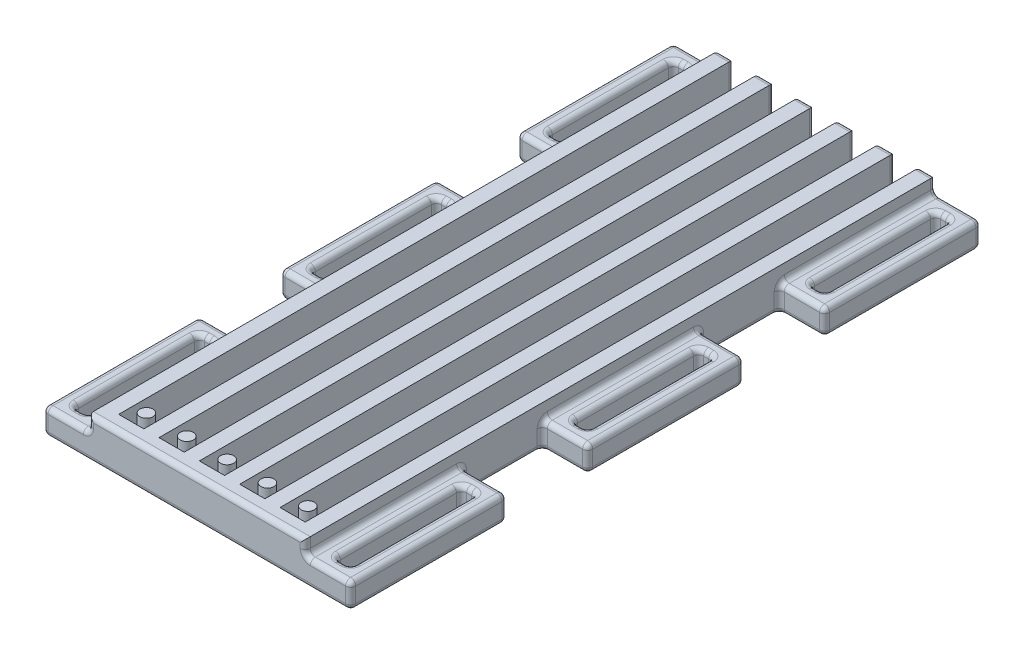
from build123d import *

# Parameters (mm, degrees)
SKETCH1_W           = 43
SKETCH1_H           = 125
BOSS_EXTRUDE2_DEPTH = 8
SKETCH2_W           = 5
SKETCH2_H           = 122
CUT_EXTRUDE1_DEPTH  = 5
SKETCH3_W           = 9
SKETCH3_H           = 31
SKETCH3_W_2         = 3
SKETCH3_H_2         = 25
BOSS_EXTRUDE3_DEPTH = 5
SKETCH4_R           = 1.3
BOSS_EXTRUDE4_DEPTH = 5
FILLET1_R           = 1


with BuildPart() as part:
    # Sketch1 → Boss-Extrude2 (new body)
    with BuildSketch(Plane(origin=(0, 0, 0), x_dir=(1, 0, 0), z_dir=(0, 1, 0))):
        with Locations((21.5, 62.5)):
            Rectangle(SKETCH1_W, SKETCH1_H)
    extrude(amount=BOSS_EXTRUDE2_DEPTH)

    # Sketch2 → Cut-Extrude1 (cut)
    with BuildSketch(Plane(origin=(0, 8, 0), x_dir=(1, 0, 0), z_dir=(0, 1, 0))):
        with Locations((5.5, 64)):
            Rectangle(SKETCH2_W, SKETCH2_H)
        with Locations((13.5, 64)):
            Rectangle(SKETCH2_W, SKETCH2_H)
        with Locations((21.5, 64)):
            Rectangle(SKETCH2_W, SKETCH2_H)
        with Locations((29.5, 64)):
            Rectangle(SKETCH2_W, SKETCH2_H)
        with Locations((37.5, 64)):
            Rectangle(SKETCH2_W, SKETCH2_H)
    extrude(amount=-CUT_EXTRUDE1_DEPTH, mode=Mode.SUBTRACT)

    # Sketch3 → Boss-Extrude3 (add)
    with BuildSketch(Plane(origin=(0, 0, 0), x_dir=(1, 0, 0), z_dir=(0, 1, 0))):
        with Locations((-4.5, 15.5)):
            Rectangle(SKETCH3_W, SKETCH3_H)
        with Locations((-4.5, 15.5)):
            Rectangle(SKETCH3_W_2, SKETCH3_H_2, mode=Mode.SUBTRACT)
        with Locations((47.5, 15.5)):
            Rectangle(SKETCH3_W, SKETCH3_H)
        with Locations((47.5, 15.5)):
            Rectangle(SKETCH3_W_2, SKETCH3_H_2, mode=Mode.SUBTRACT)
        with Locations((-4.5, 109.5)):
            Rectangle(SKETCH3_W, SKETCH3_H)
        with Locations((-4.5, 109.5)):
            Rectangle(SKETCH3_W_2, SKETCH3_H_2, mode=Mode.SUBTRACT)
        with Locations((47.5, 109.5)):
            Rectangle(SKETCH3_W, SKETCH3_H)
        with Locations((47.5, 109.5)):
            Rectangle(SKETCH3_W_2, SKETCH3_H_2, mode=Mode.SUBTRACT)
        with Locations((-4.5, 62.5)):
            Rectangle(SKETCH3_W, SKETCH3_H)
        with Locations((-4.5, 62.5)):
            Rectangle(SKETCH3_W_2, SKETCH3_H_2, mode=Mode.SUBTRACT)
        with Locations((47.5, 62.5)):
            Rectangle(SKETCH3_W, SKETCH3_H)
        with Locations((47.5, 62.5)):
            Rectangle(SKETCH3_W_2, SKETCH3_H_2, mode=Mode.SUBTRACT)
    extrude(amount=BOSS_EXTRUDE3_DEPTH)

    # Sketch4 → Boss-Extrude4 (add)
    with BuildSketch(Plane(origin=(0, 3, 0), x_dir=(1, 0, 0), z_dir=(0, 1, 0))):
        with Locations((5.5, 6)):
            Circle(SKETCH4_R)
        with Locations((13.5, 6)):
            Circle(SKETCH4_R)
        with Locations((21.5, 6)):
            Circle(SKETCH4_R)
        with Locations((29.5, 6)):
            Circle(SKETCH4_R)
        with Locations((37.5, 6)):
            Circle(SKETCH4_R)
    extrude(amount=BOSS_EXTRUDE4_DEPTH)

    # Fillet1
    fillet1_edges = [part.edges().sort_by_distance(p)[0] for p in [
        (43, 0, -39),
        (43, 5, -15.5),
        (47.5, 5, 0),
        (52, 5, -15.5),
        (47.5, 5, -31),
        (47.5, 0, -28),
        (46, 0, -15.5),
        (47.5, 0, -3),
        (49, 0, -15.5),
        (43, 2.5, -31),
        (52, 0, -15.5),
        (52, 2.5, 0),
        (47.5, 0, -31),
        (52, 2.5, -31),
        (46, 5, -15.5),
        (46, 2.5, -3),
        (47.5, 5, -3),
        (49, 2.5, -3),
        (49, 5, -15.5),
        (49, 2.5, -28),
        (47.5, 5, -28),
        (46, 2.5, -28),
        (0, 5, -109.5),
        (-4.5, 5, -125),
        (-9, 5, -109.5),
        (-4.5, 5, -94),
        (-4.5, 0, -122),
        (-6, 0, -109.5),
        (-4.5, 0, -97),
        (-3, 0, -109.5),
        (0, 2.5, -94),
        (-9, 0, -109.5),
        (-9, 2.5, -125),
        (-4.5, 0, -94),
        (-9, 2.5, -94),
        (-6, 5, -109.5),
        (-6, 2.5, -97),
        (-4.5, 5, -97),
        (-3, 2.5, -97),
        (-3, 5, -109.5),
        (-3, 2.5, -122),
        (-4.5, 5, -122),
        (-6, 2.5, -122),
        (21.5, 8, 0),
        (9.5, 8, -125),
        (43, 5, -109.5),
        (47.5, 5, -94),
        (52, 5, -109.5),
        (47.5, 5, -125),
        (46, 0, -109.5),
        (47.5, 0, -97),
        (49, 0, -109.5),
        (47.5, 0, -122),
        (47.5, 0, -94),
        (43, 2.5, -94),
        (52, 0, -109.5),
        (52, 2.5, -94),
        (52, 2.5, -125),
        (46, 5, -109.5),
        (46, 2.5, -97),
        (47.5, 5, -97),
        (49, 2.5, -97),
        (49, 5, -109.5),
        (49, 2.5, -122),
        (47.5, 5, -122),
        (46, 2.5, -122),
        (0, 0, -86),
        (0, 5, -62.5),
        (-4.5, 5, -78),
        (-9, 5, -62.5),
        (-4.5, 5, -47),
        (-4.5, 0, -75),
        (-6, 0, -62.5),
        (-4.5, 0, -50),
        (-3, 0, -62.5),
        (0, 2.5, -47),
        (-4.5, 0, -78),
        (0, 2.5, -78),
        (-9, 0, -62.5),
        (-9, 2.5, -78),
        (-4.5, 0, -47),
        (-9, 2.5, -47),
        (-6, 5, -62.5),
        (-6, 2.5, -50),
        (-4.5, 5, -50),
        (-3, 2.5, -50),
        (-3, 5, -62.5),
        (-3, 2.5, -75),
        (-4.5, 5, -75),
        (-6, 2.5, -75),
        (5.5, 3, -125),
        (3, 5.5, -125),
        (43, 0, -86),
        (43, 5, -62.5),
        (47.5, 5, -47),
        (52, 5, -62.5),
        (47.5, 5, -78),
        (46, 0, -62.5),
        (8, 5.5, -125),
        (47.5, 0, -50),
        (49, 0, -62.5),
        (47.5, 0, -75),
        (43, 2.5, -78),
        (47.5, 0, -47),
        (43, 2.5, -47),
        (52, 0, -62.5),
        (52, 2.5, -47),
        (47.5, 0, -78),
        (52, 2.5, -78),
        (46, 5, -62.5),
        (46, 2.5, -50),
        (47.5, 5, -50),
        (49, 2.5, -50),
        (49, 5, -62.5),
        (49, 2.5, -75),
        (47.5, 5, -75),
        (46, 2.5, -75),
        (17.5, 8, -125),
        (16, 5.5, -125),
        (13.5, 3, -125),
        (11, 5.5, -125),
        (25.5, 8, -125),
        (24, 5.5, -125),
        (21.5, 3, -125),
        (19, 5.5, -125),
        (21.5, 0, 0),
        (33.5, 8, -125),
        (21.5, 0, -125),
        (32, 5.5, -125),
        (29.5, 3, -125),
        (27, 5.5, -125),
        (41.5, 8, -125),
        (37.5, 3, -125),
        (35, 5.5, -125),
        (40, 5.5, -125),
        (1.5, 8, -125),
        (0, 6.5, 0),
        (43, 6.5, 0),
        (43, 6.5, -125),
        (0, 6.5, -125),
        (0, 0, -39),
        (0, 5, -15.5),
        (-4.5, 5, -31),
        (-9, 5, -15.5),
        (-4.5, 5, 0),
        (-6, 0, -15.5),
        (-4.5, 0, -3),
        (-3, 0, -15.5),
        (-4.5, 0, -28),
        (-4.5, 0, -31),
        (0, 2.5, -31),
        (-9, 0, -15.5),
        (-9, 2.5, -31),
        (-9, 2.5, 0),
        (-6, 5, -15.5),
        (-6, 2.5, -3),
        (-4.5, 5, -3),
        (-3, 2.5, -3),
        (-3, 5, -15.5),
        (-3, 2.5, -28),
        (-4.5, 5, -28),
        (-6, 2.5, -28),
    ]]
    fillet(fillet1_edges, radius=FILLET1_R)


solid = part.part
